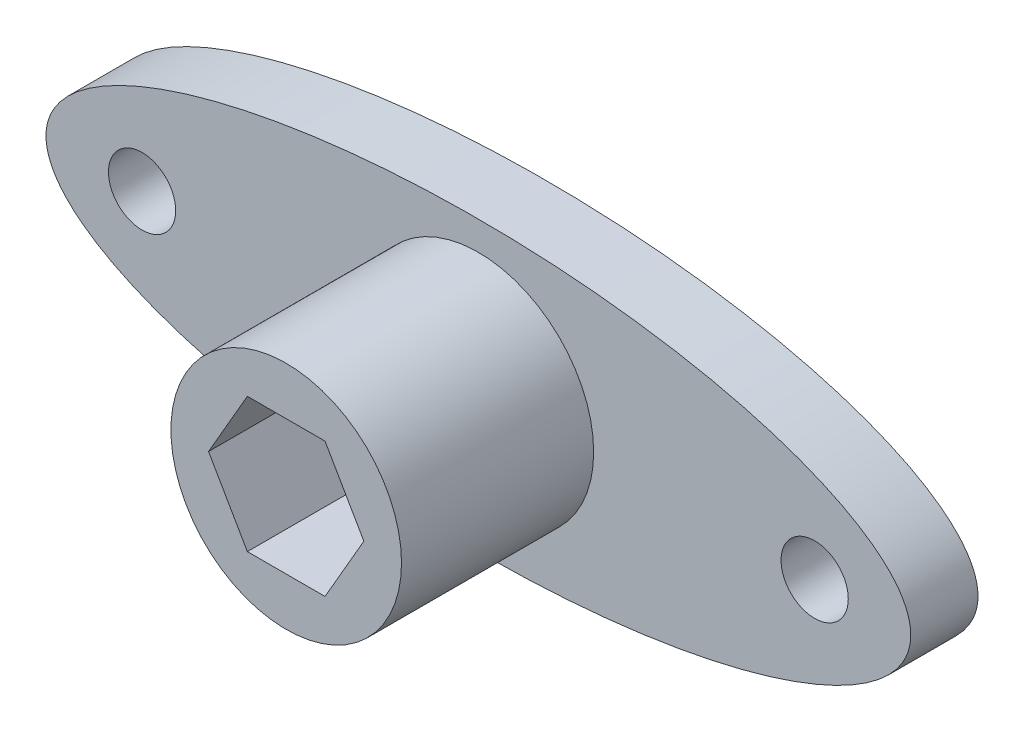
from build123d import *

# Parameters (mm, degrees)
SKETCH1_RX          = 22.5
SKETCH1_RY          = 7.5
SKETCH1_R           = 1.75
BOSS_EXTRUDE2_DEPTH = 3.5
SKETCH3_R           = 6
BOSS_EXTRUDE3_DEPTH = 10
CUT_EXTRUDE5_DEPTH  = 7


with BuildPart() as part:
    # Sketch1 → Boss-Extrude2 (new body)
    with BuildSketch(Plane.XY):
        with Locations((0, 0)):
            Ellipse(SKETCH1_RX, SKETCH1_RY)
        with Locations((-17.5, 0)):
            Circle(SKETCH1_R, mode=Mode.SUBTRACT)
        with Locations((17.5, 0)):
            Circle(SKETCH1_R, mode=Mode.SUBTRACT)
    extrude(amount=BOSS_EXTRUDE2_DEPTH)

    # Sketch3 → Boss-Extrude3 (add)
    with BuildSketch(Plane.XY.offset(3.5)):
        Circle(SKETCH3_R)
    extrude(amount=BOSS_EXTRUDE3_DEPTH)

    # Sketch4 → Cut-Extrude5 (cut)
    with BuildSketch(Plane.XY.offset(13.5)):
        Polygon((4.041451884, 0), (2.020725942, 3.5), (-2.020725942, 3.5), (-4.041451884, 0), (-2.020725942, -3.5), (2.020725942, -3.5), align=None)
    extrude(amount=-CUT_EXTRUDE5_DEPTH, mode=Mode.SUBTRACT)


solid = part.part
